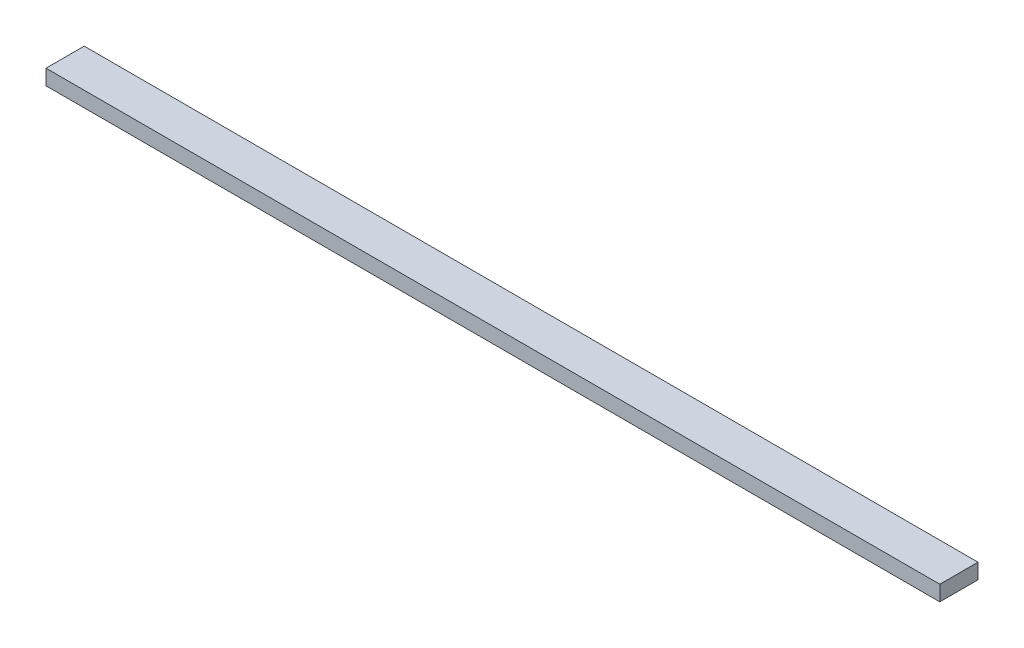
from build123d import *

# Parameters (mm, degrees)
SKETCH1_W           = 63.499998984
SKETCH1_H           = 25.4
BOSS_EXTRUDE1_DEPTH = 1486.154


with BuildPart() as part:
    # Sketch1 → Boss-Extrude1 (new body)
    with BuildSketch(Plane(origin=(0, 0, 0), x_dir=(0, 0, -1), z_dir=(1, 0, 0))):
        with Locations((31.749999492, 12.7)):
            Rectangle(SKETCH1_W, SKETCH1_H)
    extrude(amount=BOSS_EXTRUDE1_DEPTH)


solid = part.part
